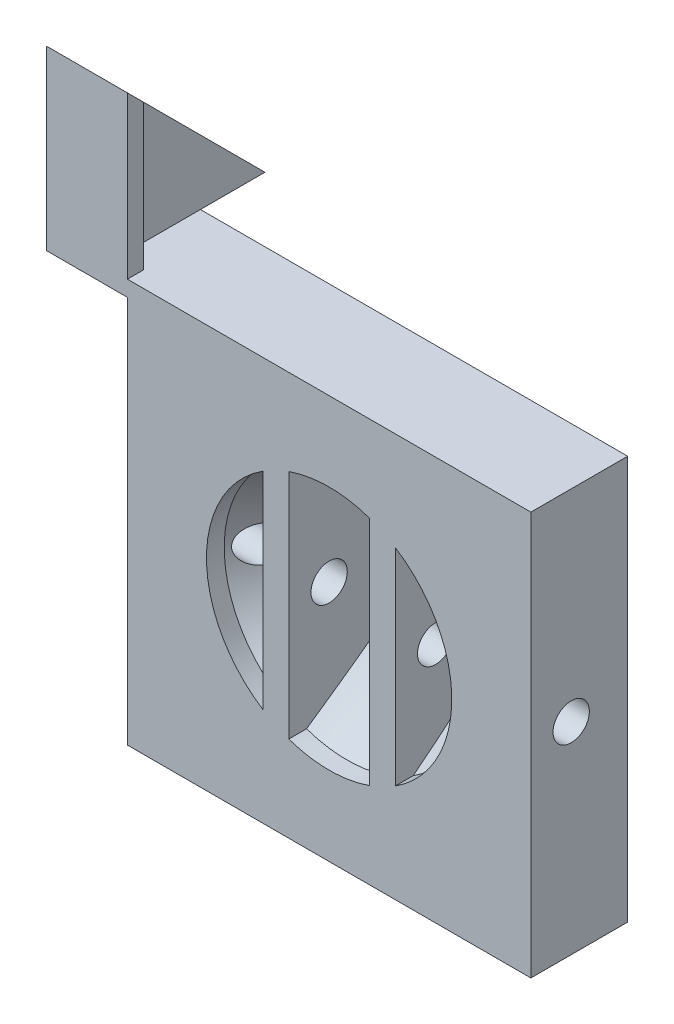
from build123d import *

# Parameters (mm, degrees)
CROQUIS1_W                                           = 50
CROQUIS1_H                                           = 50
CROQUIS1_R                                           = 2
SALIENTE_EXTRUIR2_DEPTH                              = 12
CROQUIS4_W                                           = 3.2
CROQUIS4_H                                           = 40
SALIENTE_EXTRUIR5_DEPTH                              = 10.2
CORTAR_EXTRUIR2_START                                = -50
CROQUIS7_R                                           = 2
CORTAR_EXTRUIR2_DEPTH                                = 50
REFRENTADO_PARA_TORNILLO_TAP_N_CON_CABEZ_D           = 4.5
REFRENTADO_PARA_TORNILLO_TAP_N_CON_CABEZ_CSINK_D     = 8.96
REFRENTADO_PARA_TORNILLO_TAP_N_CON_CABEZ_CSINK_ANGLE = 90
SALIENTE_EXTRUIR14_DEPTH                             = 10.05
SALIENTE_EXTRUIR15_START                             = 2.95
SALIENTE_EXTRUIR15_DEPTH                             = 1.95
SALIENTE_EXTRUIR16_START                             = 10.05
SALIENTE_EXTRUIR16_DEPTH                             = 1.95


with BuildPart() as part:
    # Croquis1 → Saliente-Extruir2 (new body)
    with BuildSketch(Plane.XY):
        Rectangle(CROQUIS1_W, CROQUIS1_H)
        Circle(CROQUIS1_R, mode=Mode.SUBTRACT)
    extrude(amount=SALIENTE_EXTRUIR2_DEPTH)

    # Croquis2 → Cortar-Revolución1 (revolve, cut)
    with BuildSketch(Plane(origin=(0, 0, 0), x_dir=(0, 0, -1), z_dir=(1, 0, 0))):
        Polygon((-12, 15.2), (-12, 0), (-1.8, 0), (-1.8, 10), (-9.8, 15.2), align=None)
    revolve(axis=Axis((0, 0, 12), (0, 0, -1)), mode=Mode.SUBTRACT)

    # Croquis4 → Saliente-Extruir5 (add)
    with BuildSketch(Plane.XY.offset(12)):
        with Locations((-6.6, 0)):
            Rectangle(CROQUIS4_W, CROQUIS4_H)
        with Locations((6.6, 0)):
            Rectangle(CROQUIS4_W, CROQUIS4_H)
    extrude(amount=-SALIENTE_EXTRUIR5_DEPTH)

    # Croquis7 → Cortar-Extruir2 (cut)
    with BuildSketch(Plane.ZY.offset(25).offset(CORTAR_EXTRUIR2_START)):
        with Locations((7, 0)):
            Circle(CROQUIS7_R)
    extrude(amount=CORTAR_EXTRUIR2_DEPTH, mode=Mode.SUBTRACT)

    # Refrentado para tornillo tap_n con cabez (through all)
    with Locations(Plane.ZY.offset(25)):
        with Locations((7, 0)):
            CounterSinkHole(REFRENTADO_PARA_TORNILLO_TAP_N_CON_CABEZ_D / 2, REFRENTADO_PARA_TORNILLO_TAP_N_CON_CABEZ_CSINK_D / 2, counter_sink_angle=REFRENTADO_PARA_TORNILLO_TAP_N_CON_CABEZ_CSINK_ANGLE)

    # Croquis17 → Refrentado para tornillo tap_n con c 2 (revolve, cut)
    with BuildSketch(Plane(origin=(0, 0, 1.8), x_dir=(0, -1, 0), z_dir=(1, 0, 0))):
        Polygon((0, 0), (0, 1.8), (2.25, 1.8), (2.25, 2.23), (4.48, 0), align=None)
    revolve(axis=Axis((0, 0, 8.15), (0, 0, -1)), mode=Mode.SUBTRACT)

    # Croquis19 → Saliente-Extruir14 (add)
    with BuildSketch(Plane.ZY.offset(25)):
        Polygon((12, 45), (10, 43), (10, 25), (0, 25), (0, 23.05), (10, 23.05), (12, 23.05), (12, 25), align=None)
    extrude(amount=SALIENTE_EXTRUIR14_DEPTH)

    # Croquis12 → Saliente-Extruir15 (add)
    with BuildSketch(Plane.ZY.offset(25).offset(SALIENTE_EXTRUIR15_START)):
        Polygon((12, 45), (-8, 25), (12, 25), align=None)
    extrude(amount=SALIENTE_EXTRUIR15_DEPTH)

    # Croquis12_3 → Saliente-Extruir16 (add)
    with BuildSketch(Plane.ZY.offset(25).offset(SALIENTE_EXTRUIR16_START)):
        Polygon((12, 45), (-8, 25), (12, 25), align=None)
    extrude(amount=-SALIENTE_EXTRUIR16_DEPTH)


solid = part.part
